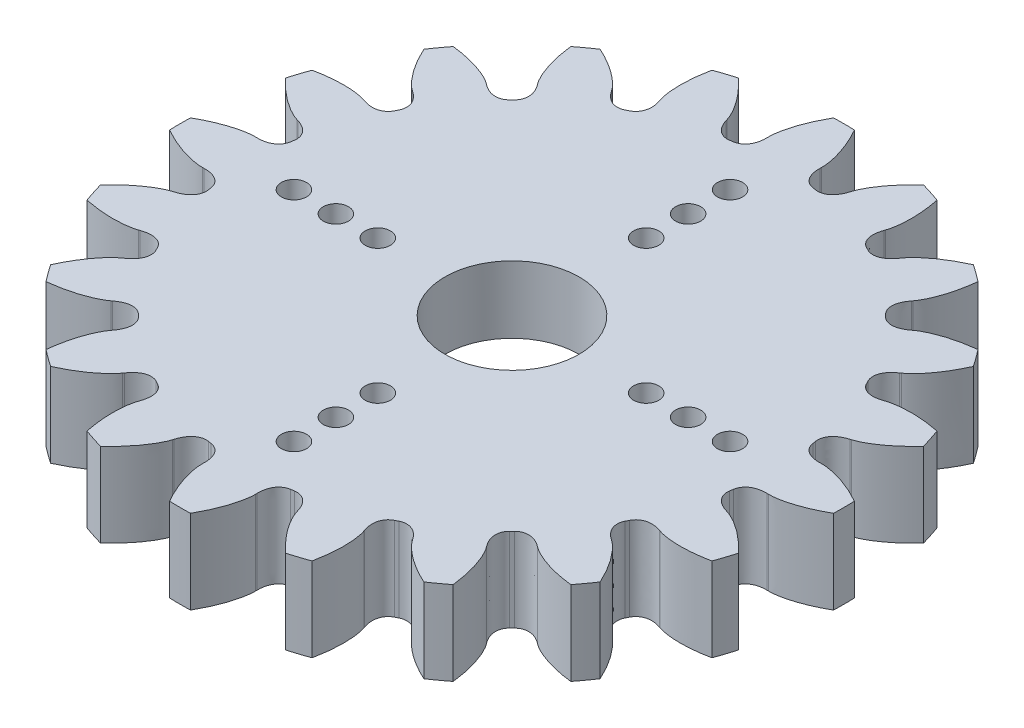
from build123d import *

# Parameters (mm, degrees)
BOSS_EXTRUDE1_DEPTH = 5
CUT_EXTRUDE2_DEPTH  = 1
FILLET1_R           = 2
SKETCH10_R          = 0.75
SKETCH10_R_2        = 4
CUT_EXTRUDE3_DEPTH  = 6.0000001


with BuildPart() as part:
    # Sketch7 → Boss-Extrude1 (new body)
    with BuildSketch(Plane(origin=(0, 0, 0), x_dir=(1, 0, 0), z_dir=(0, 1, 0))):
        with BuildLine():
            Line((-16.457739529, -3.687415298), (-16.52698002, -3.709016565))
            add(Edge.make_bspline(
                [(-16.52698002, -3.709016565), (-16.611903315, -3.73364132), (-16.770244428, -3.794438348), (-17.018736868, -3.912275662), (-17.295455662, -4.066469139), (-17.623414602, -4.278276885), (-17.995922824, -4.555042934), (-18.405597713, -4.903333775), (-18.747721316, -5.235290851), (-18.951522694, -5.45175861), (-19.014754844, -5.520787825)],
                knots=[0, 0, 0, 0, 0.062090842, 0.118994186, 0.193136179, 0.284516828, 0.393136137, 0.518994107, 0.662090741, 0.727860306, 0.727860306, 0.727860306, 0.727860306], degree=3))
            ThreePointArc((-19.014754844, -5.520787825), (-18.830919023, -6.118536489), (-18.628297477, -6.710181301))
            add(Edge.make_bspline(
                [(-18.628297477, -6.710181301), (-18.536567239, -6.728860183), (-18.244451904, -6.784194834), (-17.772548621, -6.851658542), (-17.236394454, -6.892630894), (-16.77234997, -6.897584492), (-16.382528145, -6.876171129), (-16.068025286, -6.838265047), (-15.797727644, -6.787537245), (-15.633891396, -6.743652502), (-15.550712939, -6.713657687)],
                knots=[0.272139694, 0.272139694, 0.272139694, 0.272139694, 0.337909259, 0.481005893, 0.606863863, 0.715483172, 0.806863821, 0.881005814, 0.937909158, 1, 1, 1, 1], degree=3))
            Line((-15.550712939, -6.713657687), (-15.4819993, -6.69043494))
            add(Edge.make_bspline(
                [(-15.4819993, -6.69043494), (-15.41523753, -6.666062876), (-15.302439181, -6.634063117), (-15.142393579, -6.602408879), (-15.003900862, -6.586966118), (-14.860356791, -6.585054534), (-14.708114194, -6.601356206), (-14.544296986, -6.644321677), (-14.299191223, -6.76133467), (-14.146581951, -6.923504613), (-14.079078982, -7.059889165)],
                knots=[0, 0, 0, 0, 0.134071962, 0.220864806, 0.307625499, 0.39666941, 0.491257897, 0.595715232, 0.714796253, 1, 1, 1, 1], degree=3))
            ThreePointArc((-14.079078982, -7.059889165), (-14.033352756, -7.150350371), (-13.987045304, -7.240515428))
            add(Edge.make_bspline(
                [(-13.987045304, -7.240515428), (-13.916385134, -7.375291306), (-13.874888373, -7.5940759), (-13.924292427, -7.86114914), (-13.985821969, -8.018934515), (-14.062119593, -8.151683246), (-14.148039184, -8.266689237), (-14.241936617, -8.369655172), (-14.361617878, -8.48052889), (-14.453807433, -8.552975685), (-14.51276643, -8.592661551)],
                knots=[0, 0, 0, 0, 0.285203747, 0.404284768, 0.508742103, 0.60333059, 0.692374501, 0.779135194, 0.865928038, 1, 1, 1, 1], degree=3))
            Line((-14.51276643, -8.592661551), (-14.571942892, -8.634602065))
            add(Edge.make_bspline(
                [(-14.571942892, -8.634602065), (-14.645100277, -8.68426434), (-14.77690431, -8.791015845), (-14.976820932, -8.979874177), (-15.192347738, -9.212031698), (-15.438803033, -9.51481772), (-15.707553992, -9.893149246), (-15.989550176, -10.350990023), (-16.212348679, -10.772421971), (-16.339283092, -11.041273133), (-16.37808924, -11.126463627)],
                knots=[0, 0, 0, 0, 0.062090842, 0.118994186, 0.193136179, 0.284516828, 0.393136137, 0.518994107, 0.662090741, 0.727860306, 0.727860306, 0.727860306, 0.727860306], degree=3))
            ThreePointArc((-16.37808924, -11.126463627), (-16.018536489, -11.638147995), (-15.643003646, -12.138222149))
            add(Edge.make_bspline(
                [(-15.643003646, -12.138222149), (-15.549990913, -12.127640619), (-15.255073373, -12.089998396), (-14.785419248, -12.008334062), (-14.262845181, -11.881620334), (-13.819981904, -11.742933854), (-13.45585641, -11.602106967), (-13.168460041, -11.468869412), (-12.92706746, -11.337097841), (-12.78481106, -11.244732785), (-12.714972554, -11.190502465)],
                knots=[0.272139694, 0.272139694, 0.272139694, 0.272139694, 0.337909259, 0.481005893, 0.606863863, 0.715483172, 0.806863821, 0.881005814, 0.937909158, 1, 1, 1, 1], degree=3))
            Line((-12.714972554, -11.190502465), (-12.656798223, -11.147182637))
            add(Edge.make_bspline(
                [(-12.656798223, -11.147182637), (-12.600835389, -11.103372905), (-12.503446253, -11.038082719), (-12.361015538, -10.958520939), (-12.234073213, -10.901037398), (-12.098145401, -10.854861816), (-11.948316593, -10.823320078), (-11.779240109, -10.813560368), (-11.509971672, -10.84910449), (-11.314718362, -10.956178413), (-11.208374079, -11.065028265)],
                knots=[0, 0, 0, 0, 0.134071962, 0.220864806, 0.307625499, 0.39666941, 0.491257897, 0.595715232, 0.714796253, 1, 1, 1, 1], degree=3))
            ThreePointArc((-11.208374079, -11.065028265), (-11.136931804, -11.136931804), (-11.065028265, -11.208374079))
            add(Edge.make_bspline(
                [(-11.065028265, -11.208374079), (-10.956178413, -11.314718362), (-10.84910449, -11.509971672), (-10.813560368, -11.779240109), (-10.823320078, -11.948316593), (-10.854861816, -12.098145401), (-10.901037398, -12.234073213), (-10.958520939, -12.361015538), (-11.038082719, -12.503446253), (-11.103372905, -12.600835389), (-11.147182637, -12.656798223)],
                knots=[0, 0, 0, 0, 0.285203747, 0.404284768, 0.508742103, 0.60333059, 0.692374501, 0.779135194, 0.865928038, 1, 1, 1, 1], degree=3))
            Line((-11.147182637, -12.656798223), (-11.190502465, -12.714972554))
            add(Edge.make_bspline(
                [(-11.190502465, -12.714972554), (-11.244732785, -12.78481106), (-11.337097841, -12.92706746), (-11.468869412, -13.168460041), (-11.602106967, -13.45585641), (-11.742933854, -13.819981904), (-11.881620334, -14.262845181), (-12.008334062, -14.785419248), (-12.089998396, -15.255073373), (-12.127640619, -15.549990913), (-12.138222149, -15.643003646)],
                knots=[0, 0, 0, 0, 0.062090842, 0.118994186, 0.193136179, 0.284516828, 0.393136137, 0.518994107, 0.662090741, 0.727860306, 0.727860306, 0.727860306, 0.727860306], degree=3))
            ThreePointArc((-12.138222149, -15.643003646), (-11.638147995, -16.018536489), (-11.126463627, -16.37808924))
            add(Edge.make_bspline(
                [(-11.126463627, -16.37808924), (-11.041273133, -16.339283092), (-10.772421971, -16.212348679), (-10.350990023, -15.989550176), (-9.893149246, -15.707553992), (-9.51481772, -15.438803033), (-9.212031698, -15.192347738), (-8.979874177, -14.976820932), (-8.791015845, -14.77690431), (-8.68426434, -14.645100277), (-8.634602065, -14.571942892)],
                knots=[0.272139694, 0.272139694, 0.272139694, 0.272139694, 0.337909259, 0.481005893, 0.606863863, 0.715483172, 0.806863821, 0.881005814, 0.937909158, 1, 1, 1, 1], degree=3))
            Line((-8.634602065, -14.571942892), (-8.592661551, -14.51276643))
            add(Edge.make_bspline(
                [(-8.592661551, -14.51276643), (-8.552975685, -14.453807433), (-8.48052889, -14.361617878), (-8.369655172, -14.241936617), (-8.266689237, -14.148039184), (-8.151683246, -14.062119593), (-8.018934515, -13.985821969), (-7.86114914, -13.924292427), (-7.5940759, -13.874888373), (-7.375291306, -13.916385134), (-7.240515428, -13.987045304)],
                knots=[0, 0, 0, 0, 0.134071962, 0.220864806, 0.307625499, 0.39666941, 0.491257897, 0.595715232, 0.714796253, 1, 1, 1, 1], degree=3))
            ThreePointArc((-7.240515428, -13.987045304), (-7.150350371, -14.033352756), (-7.059889165, -14.079078982))
            add(Edge.make_bspline(
                [(-7.059889165, -14.079078982), (-6.923504613, -14.146581951), (-6.76133467, -14.299191223), (-6.644321677, -14.544296986), (-6.601356206, -14.708114194), (-6.585054534, -14.860356791), (-6.586966118, -15.003900862), (-6.602408879, -15.142393579), (-6.634063117, -15.302439181), (-6.666062876, -15.41523753), (-6.69043494, -15.4819993)],
                knots=[0, 0, 0, 0, 0.285203747, 0.404284768, 0.508742103, 0.60333059, 0.692374501, 0.779135194, 0.865928038, 1, 1, 1, 1], degree=3))
            Line((-6.69043494, -15.4819993), (-6.713657687, -15.550712939))
            add(Edge.make_bspline(
                [(-6.713657687, -15.550712939), (-6.743652502, -15.633891396), (-6.787537245, -15.797727644), (-6.838265047, -16.068025286), (-6.876171129, -16.382528145), (-6.897584492, -16.77234997), (-6.892630894, -17.236394454), (-6.851658542, -17.772548621), (-6.784194834, -18.244451904), (-6.728860183, -18.536567239), (-6.710181301, -18.628297477)],
                knots=[0, 0, 0, 0, 0.062090842, 0.118994186, 0.193136179, 0.284516828, 0.393136137, 0.518994107, 0.662090741, 0.727860306, 0.727860306, 0.727860306, 0.727860306], degree=3))
            ThreePointArc((-6.710181301, -18.628297477), (-6.118536489, -18.830919023), (-5.520787825, -19.014754844))
            add(Edge.make_bspline(
                [(-5.520787825, -19.014754844), (-5.45175861, -18.951522694), (-5.235290851, -18.747721316), (-4.903333775, -18.405597713), (-4.555042934, -17.995922824), (-4.278276885, -17.623414602), (-4.066469139, -17.295455662), (-3.912275662, -17.018736868), (-3.794438348, -16.770244428), (-3.73364132, -16.611903315), (-3.709016565, -16.52698002)],
                knots=[0.272139694, 0.272139694, 0.272139694, 0.272139694, 0.337909259, 0.481005893, 0.606863863, 0.715483172, 0.806863821, 0.881005814, 0.937909158, 1, 1, 1, 1], degree=3))
            Line((-3.709016565, -16.52698002), (-3.687415298, -16.457739529))
            add(Edge.make_bspline(
                [(-3.687415298, -16.457739529), (-3.667891129, -16.389402584), (-3.627478271, -16.279337816), (-3.559014643, -16.131252309), (-3.490104122, -16.010132321), (-3.407277539, -15.892879127), (-3.304603255, -15.779294161), (-3.17355412, -15.672017727), (-2.934819068, -15.54250151), (-2.713919349, -15.514359117), (-2.563904679, -15.539912895)],
                knots=[0, 0, 0, 0, 0.134071962, 0.220864806, 0.307625499, 0.39666941, 0.491257897, 0.595715232, 0.714796253, 1, 1, 1, 1], degree=3))
            ThreePointArc((-2.563904679, -15.539912895), (-2.463842824, -15.556091364), (-2.363678924, -15.57162554))
            add(Edge.make_bspline(
                [(-2.363678924, -15.57162554), (-2.213109942, -15.593679534), (-2.011718303, -15.688706308), (-1.824690488, -15.885656738), (-1.733205595, -16.0281791), (-1.670656234, -16.167932921), (-1.628116701, -16.305042156), (-1.600007036, -16.441528633), (-1.580655195, -16.603522743), (-1.576232167, -16.720688818), (-1.578780856, -16.791714415)],
                knots=[0, 0, 0, 0, 0.285203747, 0.404284768, 0.508742103, 0.60333059, 0.692374501, 0.779135194, 0.865928038, 1, 1, 1, 1], degree=3))
            Line((-1.578780856, -16.791714415), (-1.579633319, -16.864241194))
            add(Edge.make_bspline(
                [(-1.579633319, -16.864241194), (-1.582456526, -16.952617514), (-1.573565212, -17.121996177), (-1.538283653, -17.394740264), (-1.477147752, -17.70556388), (-1.377051501, -18.08292356), (-1.228942718, -18.522725345), (-1.024294947, -19.019977107), (-0.814307014, -19.447936366), (-0.67141203, -19.708655212), (-0.625301155, -19.790123761)],
                knots=[0, 0, 0, 0, 0.062090842, 0.118994186, 0.193136179, 0.284516828, 0.393136137, 0.518994107, 0.662090741, 0.727860306, 0.727860306, 0.727860306, 0.727860306], degree=3))
            ThreePointArc((-0.625301155, -19.790123761), (0, -19.8), (0.625301155, -19.790123761))
            add(Edge.make_bspline(
                [(0.625301155, -19.790123761), (0.67141203, -19.708655212), (0.814307014, -19.447936366), (1.024294947, -19.019977107), (1.228942718, -18.522725345), (1.377051501, -18.08292356), (1.477147752, -17.70556388), (1.538283653, -17.394740264), (1.573565212, -17.121996177), (1.582456526, -16.952617514), (1.579633319, -16.864241194)],
                knots=[0.272139694, 0.272139694, 0.272139694, 0.272139694, 0.337909259, 0.481005893, 0.606863863, 0.715483172, 0.806863821, 0.881005814, 0.937909158, 1, 1, 1, 1], degree=3))
            Line((1.579633319, -16.864241194), (1.578780856, -16.791714415))
            add(Edge.make_bspline(
                [(1.578780856, -16.791714415), (1.576232167, -16.720688818), (1.580655195, -16.603522743), (1.600007036, -16.441528633), (1.628116701, -16.305042156), (1.670656234, -16.167932921), (1.733205595, -16.0281791), (1.824690488, -15.885656738), (2.011718303, -15.688706308), (2.213109942, -15.593679534), (2.363678924, -15.57162554)],
                knots=[0, 0, 0, 0, 0.134071962, 0.220864806, 0.307625499, 0.39666941, 0.491257897, 0.595715232, 0.714796253, 1, 1, 1, 1], degree=3))
            ThreePointArc((2.363678924, -15.57162554), (2.463842824, -15.556091364), (2.563904679, -15.539912895))
            add(Edge.make_bspline(
                [(2.563904679, -15.539912895), (2.713919349, -15.514359117), (2.934819068, -15.54250151), (3.17355412, -15.672017727), (3.304603255, -15.779294161), (3.407277539, -15.892879127), (3.490104122, -16.010132321), (3.559014643, -16.131252309), (3.627478271, -16.279337816), (3.667891129, -16.389402584), (3.687415298, -16.457739529)],
                knots=[0, 0, 0, 0, 0.285203747, 0.404284768, 0.508742103, 0.60333059, 0.692374501, 0.779135194, 0.865928038, 1, 1, 1, 1], degree=3))
            Line((3.687415298, -16.457739529), (3.709016565, -16.52698002))
            add(Edge.make_bspline(
                [(3.709016565, -16.52698002), (3.73364132, -16.611903315), (3.794438348, -16.770244428), (3.912275662, -17.018736868), (4.066469139, -17.295455662), (4.278276885, -17.623414602), (4.555042934, -17.995922824), (4.903333775, -18.405597713), (5.235290851, -18.747721316), (5.45175861, -18.951522694), (5.520787825, -19.014754844)],
                knots=[0, 0, 0, 0, 0.062090842, 0.118994186, 0.193136179, 0.284516828, 0.393136137, 0.518994107, 0.662090741, 0.727860306, 0.727860306, 0.727860306, 0.727860306], degree=3))
            ThreePointArc((5.520787825, -19.014754844), (6.118536489, -18.830919023), (6.710181301, -18.628297477))
            add(Edge.make_bspline(
                [(6.710181301, -18.628297477), (6.728860183, -18.536567239), (6.784194834, -18.244451904), (6.851658542, -17.772548621), (6.892630894, -17.236394454), (6.897584492, -16.77234997), (6.876171129, -16.382528145), (6.838265047, -16.068025286), (6.787537245, -15.797727644), (6.743652502, -15.633891396), (6.713657687, -15.550712939)],
                knots=[0.272139694, 0.272139694, 0.272139694, 0.272139694, 0.337909259, 0.481005893, 0.606863863, 0.715483172, 0.806863821, 0.881005814, 0.937909158, 1, 1, 1, 1], degree=3))
            Line((6.713657687, -15.550712939), (6.69043494, -15.4819993))
            add(Edge.make_bspline(
                [(6.69043494, -15.4819993), (6.666062876, -15.41523753), (6.634063117, -15.302439181), (6.602408879, -15.142393579), (6.586966118, -15.003900862), (6.585054534, -14.860356791), (6.601356206, -14.708114194), (6.644321677, -14.544296986), (6.76133467, -14.299191223), (6.923504613, -14.146581951), (7.059889165, -14.079078982)],
                knots=[0, 0, 0, 0, 0.134071962, 0.220864806, 0.307625499, 0.39666941, 0.491257897, 0.595715232, 0.714796253, 1, 1, 1, 1], degree=3))
            ThreePointArc((7.059889165, -14.079078982), (7.150350371, -14.033352756), (7.240515428, -13.987045304))
            add(Edge.make_bspline(
                [(7.240515428, -13.987045304), (7.375291306, -13.916385134), (7.5940759, -13.874888373), (7.86114914, -13.924292427), (8.018934515, -13.985821969), (8.151683246, -14.062119593), (8.266689237, -14.148039184), (8.369655172, -14.241936617), (8.48052889, -14.361617878), (8.552975685, -14.453807433), (8.592661551, -14.51276643)],
                knots=[0, 0, 0, 0, 0.285203747, 0.404284768, 0.508742103, 0.60333059, 0.692374501, 0.779135194, 0.865928038, 1, 1, 1, 1], degree=3))
            Line((8.592661551, -14.51276643), (8.634602065, -14.571942892))
            add(Edge.make_bspline(
                [(8.634602065, -14.571942892), (8.68426434, -14.645100277), (8.791015845, -14.77690431), (8.979874177, -14.976820932), (9.212031698, -15.192347738), (9.51481772, -15.438803033), (9.893149246, -15.707553992), (10.350990023, -15.989550176), (10.772421971, -16.212348679), (11.041273133, -16.339283092), (11.126463627, -16.37808924)],
                knots=[0, 0, 0, 0, 0.062090842, 0.118994186, 0.193136179, 0.284516828, 0.393136137, 0.518994107, 0.662090741, 0.727860306, 0.727860306, 0.727860306, 0.727860306], degree=3))
            ThreePointArc((11.126463627, -16.37808924), (11.638147995, -16.018536489), (12.138222149, -15.643003646))
            add(Edge.make_bspline(
                [(12.138222149, -15.643003646), (12.127640619, -15.549990913), (12.089998396, -15.255073373), (12.008334062, -14.785419248), (11.881620334, -14.262845181), (11.742933854, -13.819981904), (11.602106967, -13.45585641), (11.468869412, -13.168460041), (11.337097841, -12.92706746), (11.244732785, -12.78481106), (11.190502465, -12.714972554)],
                knots=[0.272139694, 0.272139694, 0.272139694, 0.272139694, 0.337909259, 0.481005893, 0.606863863, 0.715483172, 0.806863821, 0.881005814, 0.937909158, 1, 1, 1, 1], degree=3))
            Line((11.190502465, -12.714972554), (11.147182637, -12.656798223))
            add(Edge.make_bspline(
                [(11.147182637, -12.656798223), (11.103372905, -12.600835389), (11.038082719, -12.503446253), (10.958520939, -12.361015538), (10.901037398, -12.234073213), (10.854861816, -12.098145401), (10.823320078, -11.948316593), (10.813560368, -11.779240109), (10.84910449, -11.509971672), (10.956178413, -11.314718362), (11.065028265, -11.208374079)],
                knots=[0, 0, 0, 0, 0.134071962, 0.220864806, 0.307625499, 0.39666941, 0.491257897, 0.595715232, 0.714796253, 1, 1, 1, 1], degree=3))
            ThreePointArc((11.065028265, -11.208374079), (11.136931804, -11.136931804), (11.208374079, -11.065028265))
            add(Edge.make_bspline(
                [(11.208374079, -11.065028265), (11.314718362, -10.956178413), (11.509971672, -10.84910449), (11.779240109, -10.813560368), (11.948316593, -10.823320078), (12.098145401, -10.854861816), (12.234073213, -10.901037398), (12.361015538, -10.958520939), (12.503446253, -11.038082719), (12.600835389, -11.103372905), (12.656798223, -11.147182637)],
                knots=[0, 0, 0, 0, 0.285203747, 0.404284768, 0.508742103, 0.60333059, 0.692374501, 0.779135194, 0.865928038, 1, 1, 1, 1], degree=3))
            Line((12.656798223, -11.147182637), (12.714972554, -11.190502465))
            add(Edge.make_bspline(
                [(12.714972554, -11.190502465), (12.78481106, -11.244732785), (12.92706746, -11.337097841), (13.168460041, -11.468869412), (13.45585641, -11.602106967), (13.819981904, -11.742933854), (14.262845181, -11.881620334), (14.785419248, -12.008334062), (15.255073373, -12.089998396), (15.549990913, -12.127640619), (15.643003646, -12.138222149)],
                knots=[0, 0, 0, 0, 0.062090842, 0.118994186, 0.193136179, 0.284516828, 0.393136137, 0.518994107, 0.662090741, 0.727860306, 0.727860306, 0.727860306, 0.727860306], degree=3))
            ThreePointArc((15.643003646, -12.138222149), (16.018536489, -11.638147995), (16.37808924, -11.126463627))
            add(Edge.make_bspline(
                [(16.37808924, -11.126463627), (16.339283092, -11.041273133), (16.212348679, -10.772421971), (15.989550176, -10.350990023), (15.707553992, -9.893149246), (15.438803033, -9.51481772), (15.192347738, -9.212031698), (14.976820932, -8.979874177), (14.77690431, -8.791015845), (14.645100277, -8.68426434), (14.571942892, -8.634602065)],
                knots=[0.272139694, 0.272139694, 0.272139694, 0.272139694, 0.337909259, 0.481005893, 0.606863863, 0.715483172, 0.806863821, 0.881005814, 0.937909158, 1, 1, 1, 1], degree=3))
            Line((14.571942892, -8.634602065), (14.51276643, -8.592661551))
            add(Edge.make_bspline(
                [(14.51276643, -8.592661551), (14.453807433, -8.552975685), (14.361617878, -8.48052889), (14.241936617, -8.369655172), (14.148039184, -8.266689237), (14.062119593, -8.151683246), (13.985821969, -8.018934515), (13.924292427, -7.86114914), (13.874888373, -7.5940759), (13.916385134, -7.375291306), (13.987045304, -7.240515428)],
                knots=[0, 0, 0, 0, 0.134071962, 0.220864806, 0.307625499, 0.39666941, 0.491257897, 0.595715232, 0.714796253, 1, 1, 1, 1], degree=3))
            ThreePointArc((13.987045304, -7.240515428), (14.033352756, -7.150350371), (14.079078982, -7.059889165))
            add(Edge.make_bspline(
                [(14.079078982, -7.059889165), (14.146581951, -6.923504613), (14.299191223, -6.76133467), (14.544296986, -6.644321677), (14.708114194, -6.601356206), (14.860356791, -6.585054534), (15.003900862, -6.586966118), (15.142393579, -6.602408879), (15.302439181, -6.634063117), (15.41523753, -6.666062876), (15.4819993, -6.69043494)],
                knots=[0, 0, 0, 0, 0.285203747, 0.404284768, 0.508742103, 0.60333059, 0.692374501, 0.779135194, 0.865928038, 1, 1, 1, 1], degree=3))
            Line((15.4819993, -6.69043494), (15.550712939, -6.713657687))
            add(Edge.make_bspline(
                [(15.550712939, -6.713657687), (15.633891396, -6.743652502), (15.797727644, -6.787537245), (16.068025286, -6.838265047), (16.382528145, -6.876171129), (16.77234997, -6.897584492), (17.236394454, -6.892630894), (17.772548621, -6.851658542), (18.244451904, -6.784194834), (18.536567239, -6.728860183), (18.628297477, -6.710181301)],
                knots=[0, 0, 0, 0, 0.062090842, 0.118994186, 0.193136179, 0.284516828, 0.393136137, 0.518994107, 0.662090741, 0.727860306, 0.727860306, 0.727860306, 0.727860306], degree=3))
            ThreePointArc((18.628297477, -6.710181301), (18.830919023, -6.118536489), (19.014754844, -5.520787825))
            add(Edge.make_bspline(
                [(19.014754844, -5.520787825), (18.951522694, -5.45175861), (18.747721316, -5.235290851), (18.405597713, -4.903333775), (17.995922824, -4.555042934), (17.623414602, -4.278276885), (17.295455662, -4.066469139), (17.018736868, -3.912275662), (16.770244428, -3.794438348), (16.611903315, -3.73364132), (16.52698002, -3.709016565)],
                knots=[0.272139694, 0.272139694, 0.272139694, 0.272139694, 0.337909259, 0.481005893, 0.606863863, 0.715483172, 0.806863821, 0.881005814, 0.937909158, 1, 1, 1, 1], degree=3))
            Line((16.52698002, -3.709016565), (16.457739529, -3.687415298))
            add(Edge.make_bspline(
                [(16.457739529, -3.687415298), (16.389402584, -3.667891129), (16.279337816, -3.627478271), (16.131252309, -3.559014643), (16.010132321, -3.490104122), (15.892879127, -3.407277539), (15.779294161, -3.304603255), (15.672017727, -3.17355412), (15.54250151, -2.934819068), (15.514359117, -2.713919349), (15.539912895, -2.563904679)],
                knots=[0, 0, 0, 0, 0.134071962, 0.220864806, 0.307625499, 0.39666941, 0.491257897, 0.595715232, 0.714796253, 1, 1, 1, 1], degree=3))
            ThreePointArc((15.539912895, -2.563904679), (15.556091364, -2.463842824), (15.57162554, -2.363678924))
            add(Edge.make_bspline(
                [(15.57162554, -2.363678924), (15.593679534, -2.213109942), (15.688706308, -2.011718303), (15.885656738, -1.824690488), (16.0281791, -1.733205595), (16.167932921, -1.670656234), (16.305042156, -1.628116701), (16.441528633, -1.600007036), (16.603522743, -1.580655195), (16.720688818, -1.576232167), (16.791714415, -1.578780856)],
                knots=[0, 0, 0, 0, 0.285203747, 0.404284768, 0.508742103, 0.60333059, 0.692374501, 0.779135194, 0.865928038, 1, 1, 1, 1], degree=3))
            Line((16.791714415, -1.578780856), (16.864241194, -1.579633319))
            add(Edge.make_bspline(
                [(16.864241194, -1.579633319), (16.952617514, -1.582456526), (17.121996177, -1.573565212), (17.394740264, -1.538283653), (17.70556388, -1.477147752), (18.08292356, -1.377051501), (18.522725345, -1.228942718), (19.019977107, -1.024294947), (19.447936366, -0.814307014), (19.708655212, -0.67141203), (19.790123761, -0.625301155)],
                knots=[0, 0, 0, 0, 0.062090842, 0.118994186, 0.193136179, 0.284516828, 0.393136137, 0.518994107, 0.662090741, 0.727860306, 0.727860306, 0.727860306, 0.727860306], degree=3))
            ThreePointArc((19.790123761, -0.625301155), (19.8, 0), (19.790123761, 0.625301155))
            add(Edge.make_bspline(
                [(19.790123761, 0.625301155), (19.708655212, 0.67141203), (19.447936366, 0.814307014), (19.019977107, 1.024294947), (18.522725345, 1.228942718), (18.08292356, 1.377051501), (17.70556388, 1.477147752), (17.394740264, 1.538283653), (17.121996177, 1.573565212), (16.952617514, 1.582456526), (16.864241194, 1.579633319)],
                knots=[0.272139694, 0.272139694, 0.272139694, 0.272139694, 0.337909259, 0.481005893, 0.606863863, 0.715483172, 0.806863821, 0.881005814, 0.937909158, 1, 1, 1, 1], degree=3))
            Line((16.864241194, 1.579633319), (16.791714415, 1.578780856))
            add(Edge.make_bspline(
                [(16.791714415, 1.578780856), (16.720688818, 1.576232167), (16.603522743, 1.580655195), (16.441528633, 1.600007036), (16.305042156, 1.628116701), (16.167932921, 1.670656234), (16.0281791, 1.733205595), (15.885656738, 1.824690488), (15.688706308, 2.011718303), (15.593679534, 2.213109942), (15.57162554, 2.363678924)],
                knots=[0, 0, 0, 0, 0.134071962, 0.220864806, 0.307625499, 0.39666941, 0.491257897, 0.595715232, 0.714796253, 1, 1, 1, 1], degree=3))
            ThreePointArc((15.57162554, 2.363678924), (15.556091364, 2.463842824), (15.539912895, 2.563904679))
            add(Edge.make_bspline(
                [(15.539912895, 2.563904679), (15.514359117, 2.713919349), (15.54250151, 2.934819068), (15.672017727, 3.17355412), (15.779294161, 3.304603255), (15.892879127, 3.407277539), (16.010132321, 3.490104122), (16.131252309, 3.559014643), (16.279337816, 3.627478271), (16.389402584, 3.667891129), (16.457739529, 3.687415298)],
                knots=[0, 0, 0, 0, 0.285203747, 0.404284768, 0.508742103, 0.60333059, 0.692374501, 0.779135194, 0.865928038, 1, 1, 1, 1], degree=3))
            Line((16.457739529, 3.687415298), (16.52698002, 3.709016565))
            add(Edge.make_bspline(
                [(16.52698002, 3.709016565), (16.611903315, 3.73364132), (16.770244428, 3.794438348), (17.018736868, 3.912275662), (17.295455662, 4.066469139), (17.623414602, 4.278276885), (17.995922824, 4.555042934), (18.405597713, 4.903333775), (18.747721316, 5.235290851), (18.951522694, 5.45175861), (19.014754844, 5.520787825)],
                knots=[0, 0, 0, 0, 0.062090842, 0.118994186, 0.193136179, 0.284516828, 0.393136137, 0.518994107, 0.662090741, 0.727860306, 0.727860306, 0.727860306, 0.727860306], degree=3))
            ThreePointArc((19.014754844, 5.520787825), (18.830919023, 6.118536489), (18.628297477, 6.710181301))
            add(Edge.make_bspline(
                [(18.628297477, 6.710181301), (18.536567239, 6.728860183), (18.244451904, 6.784194834), (17.772548621, 6.851658542), (17.236394454, 6.892630894), (16.77234997, 6.897584492), (16.382528145, 6.876171129), (16.068025286, 6.838265047), (15.797727644, 6.787537245), (15.633891396, 6.743652502), (15.550712939, 6.713657687)],
                knots=[0.272139694, 0.272139694, 0.272139694, 0.272139694, 0.337909259, 0.481005893, 0.606863863, 0.715483172, 0.806863821, 0.881005814, 0.937909158, 1, 1, 1, 1], degree=3))
            Line((15.550712939, 6.713657687), (15.4819993, 6.69043494))
            add(Edge.make_bspline(
                [(15.4819993, 6.69043494), (15.41523753, 6.666062876), (15.302439181, 6.634063117), (15.142393579, 6.602408879), (15.003900862, 6.586966118), (14.860356791, 6.585054534), (14.708114194, 6.601356206), (14.544296986, 6.644321677), (14.299191223, 6.76133467), (14.146581951, 6.923504613), (14.079078982, 7.059889165)],
                knots=[0, 0, 0, 0, 0.134071962, 0.220864806, 0.307625499, 0.39666941, 0.491257897, 0.595715232, 0.714796253, 1, 1, 1, 1], degree=3))
            ThreePointArc((14.079078982, 7.059889165), (14.033352756, 7.150350371), (13.987045304, 7.240515428))
            add(Edge.make_bspline(
                [(13.987045304, 7.240515428), (13.916385134, 7.375291306), (13.874888373, 7.5940759), (13.924292427, 7.86114914), (13.985821969, 8.018934515), (14.062119593, 8.151683246), (14.148039184, 8.266689237), (14.241936617, 8.369655172), (14.361617878, 8.48052889), (14.453807433, 8.552975685), (14.51276643, 8.592661551)],
                knots=[0, 0, 0, 0, 0.285203747, 0.404284768, 0.508742103, 0.60333059, 0.692374501, 0.779135194, 0.865928038, 1, 1, 1, 1], degree=3))
            Line((14.51276643, 8.592661551), (14.571942892, 8.634602065))
            add(Edge.make_bspline(
                [(14.571942892, 8.634602065), (14.645100277, 8.68426434), (14.77690431, 8.791015845), (14.976820932, 8.979874177), (15.192347738, 9.212031698), (15.438803033, 9.51481772), (15.707553992, 9.893149246), (15.989550176, 10.350990023), (16.212348679, 10.772421971), (16.339283092, 11.041273133), (16.37808924, 11.126463627)],
                knots=[0, 0, 0, 0, 0.062090842, 0.118994186, 0.193136179, 0.284516828, 0.393136137, 0.518994107, 0.662090741, 0.727860306, 0.727860306, 0.727860306, 0.727860306], degree=3))
            ThreePointArc((16.37808924, 11.126463627), (16.018536489, 11.638147995), (15.643003646, 12.138222149))
            add(Edge.make_bspline(
                [(15.643003646, 12.138222149), (15.549990913, 12.127640619), (15.255073373, 12.089998396), (14.785419248, 12.008334062), (14.262845181, 11.881620334), (13.819981904, 11.742933854), (13.45585641, 11.602106967), (13.168460041, 11.468869412), (12.92706746, 11.337097841), (12.78481106, 11.244732785), (12.714972554, 11.190502465)],
                knots=[0.272139694, 0.272139694, 0.272139694, 0.272139694, 0.337909259, 0.481005893, 0.606863863, 0.715483172, 0.806863821, 0.881005814, 0.937909158, 1, 1, 1, 1], degree=3))
            Line((12.714972554, 11.190502465), (12.656798223, 11.147182637))
            add(Edge.make_bspline(
                [(12.656798223, 11.147182637), (12.600835389, 11.103372905), (12.503446253, 11.038082719), (12.361015538, 10.958520939), (12.234073213, 10.901037398), (12.098145401, 10.854861816), (11.948316593, 10.823320078), (11.779240109, 10.813560368), (11.509971672, 10.84910449), (11.314718362, 10.956178413), (11.208374079, 11.065028265)],
                knots=[0, 0, 0, 0, 0.134071962, 0.220864806, 0.307625499, 0.39666941, 0.491257897, 0.595715232, 0.714796253, 1, 1, 1, 1], degree=3))
            ThreePointArc((11.208374079, 11.065028265), (11.136931804, 11.136931804), (11.065028265, 11.208374079))
            add(Edge.make_bspline(
                [(11.065028265, 11.208374079), (10.956178413, 11.314718362), (10.84910449, 11.509971672), (10.813560368, 11.779240109), (10.823320078, 11.948316593), (10.854861816, 12.098145401), (10.901037398, 12.234073213), (10.958520939, 12.361015538), (11.038082719, 12.503446253), (11.103372905, 12.600835389), (11.147182637, 12.656798223)],
                knots=[0, 0, 0, 0, 0.285203747, 0.404284768, 0.508742103, 0.60333059, 0.692374501, 0.779135194, 0.865928038, 1, 1, 1, 1], degree=3))
            Line((11.147182637, 12.656798223), (11.190502465, 12.714972554))
            add(Edge.make_bspline(
                [(11.190502465, 12.714972554), (11.244732785, 12.78481106), (11.337097841, 12.92706746), (11.468869412, 13.168460041), (11.602106967, 13.45585641), (11.742933854, 13.819981904), (11.881620334, 14.262845181), (12.008334062, 14.785419248), (12.089998396, 15.255073373), (12.127640619, 15.549990913), (12.138222149, 15.643003646)],
                knots=[0, 0, 0, 0, 0.062090842, 0.118994186, 0.193136179, 0.284516828, 0.393136137, 0.518994107, 0.662090741, 0.727860306, 0.727860306, 0.727860306, 0.727860306], degree=3))
            ThreePointArc((12.138222149, 15.643003646), (11.638147995, 16.018536489), (11.126463627, 16.37808924))
            add(Edge.make_bspline(
                [(11.126463627, 16.37808924), (11.041273133, 16.339283092), (10.772421971, 16.212348679), (10.350990023, 15.989550176), (9.893149246, 15.707553992), (9.51481772, 15.438803033), (9.212031698, 15.192347738), (8.979874177, 14.976820932), (8.791015845, 14.77690431), (8.68426434, 14.645100277), (8.634602065, 14.571942892)],
                knots=[0.272139694, 0.272139694, 0.272139694, 0.272139694, 0.337909259, 0.481005893, 0.606863863, 0.715483172, 0.806863821, 0.881005814, 0.937909158, 1, 1, 1, 1], degree=3))
            Line((8.634602065, 14.571942892), (8.592661551, 14.51276643))
            add(Edge.make_bspline(
                [(8.592661551, 14.51276643), (8.552975685, 14.453807433), (8.48052889, 14.361617878), (8.369655172, 14.241936617), (8.266689237, 14.148039184), (8.151683246, 14.062119593), (8.018934515, 13.985821969), (7.86114914, 13.924292427), (7.5940759, 13.874888373), (7.375291306, 13.916385134), (7.240515428, 13.987045304)],
                knots=[0, 0, 0, 0, 0.134071962, 0.220864806, 0.307625499, 0.39666941, 0.491257897, 0.595715232, 0.714796253, 1, 1, 1, 1], degree=3))
            ThreePointArc((7.240515428, 13.987045304), (7.150350371, 14.033352756), (7.059889165, 14.079078982))
            add(Edge.make_bspline(
                [(7.059889165, 14.079078982), (6.923504613, 14.146581951), (6.76133467, 14.299191223), (6.644321677, 14.544296986), (6.601356206, 14.708114194), (6.585054534, 14.860356791), (6.586966118, 15.003900862), (6.602408879, 15.142393579), (6.634063117, 15.302439181), (6.666062876, 15.41523753), (6.69043494, 15.4819993)],
                knots=[0, 0, 0, 0, 0.285203747, 0.404284768, 0.508742103, 0.60333059, 0.692374501, 0.779135194, 0.865928038, 1, 1, 1, 1], degree=3))
            Line((6.69043494, 15.4819993), (6.713657687, 15.550712939))
            add(Edge.make_bspline(
                [(6.713657687, 15.550712939), (6.743652502, 15.633891396), (6.787537245, 15.797727644), (6.838265047, 16.068025286), (6.876171129, 16.382528145), (6.897584492, 16.77234997), (6.892630894, 17.236394454), (6.851658542, 17.772548621), (6.784194834, 18.244451904), (6.728860183, 18.536567239), (6.710181301, 18.628297477)],
                knots=[0, 0, 0, 0, 0.062090842, 0.118994186, 0.193136179, 0.284516828, 0.393136137, 0.518994107, 0.662090741, 0.727860306, 0.727860306, 0.727860306, 0.727860306], degree=3))
            ThreePointArc((6.710181301, 18.628297477), (6.118536489, 18.830919023), (5.520787825, 19.014754844))
            add(Edge.make_bspline(
                [(5.520787825, 19.014754844), (5.45175861, 18.951522694), (5.235290851, 18.747721316), (4.903333775, 18.405597713), (4.555042934, 17.995922824), (4.278276885, 17.623414602), (4.066469139, 17.295455662), (3.912275662, 17.018736868), (3.794438348, 16.770244428), (3.73364132, 16.611903315), (3.709016565, 16.52698002)],
                knots=[0.272139694, 0.272139694, 0.272139694, 0.272139694, 0.337909259, 0.481005893, 0.606863863, 0.715483172, 0.806863821, 0.881005814, 0.937909158, 1, 1, 1, 1], degree=3))
            Line((3.709016565, 16.52698002), (3.687415298, 16.457739529))
            add(Edge.make_bspline(
                [(3.687415298, 16.457739529), (3.667891129, 16.389402584), (3.627478271, 16.279337816), (3.559014643, 16.131252309), (3.490104122, 16.010132321), (3.407277539, 15.892879127), (3.304603255, 15.779294161), (3.17355412, 15.672017727), (2.934819068, 15.54250151), (2.713919349, 15.514359117), (2.563904679, 15.539912895)],
                knots=[0, 0, 0, 0, 0.134071962, 0.220864806, 0.307625499, 0.39666941, 0.491257897, 0.595715232, 0.714796253, 1, 1, 1, 1], degree=3))
            ThreePointArc((2.563904679, 15.539912895), (2.463842824, 15.556091364), (2.363678924, 15.57162554))
            add(Edge.make_bspline(
                [(2.363678924, 15.57162554), (2.213109942, 15.593679534), (2.011718303, 15.688706308), (1.824690488, 15.885656738), (1.733205595, 16.0281791), (1.670656234, 16.167932921), (1.628116701, 16.305042156), (1.600007036, 16.441528633), (1.580655195, 16.603522743), (1.576232167, 16.720688818), (1.578780856, 16.791714415)],
                knots=[0, 0, 0, 0, 0.285203747, 0.404284768, 0.508742103, 0.60333059, 0.692374501, 0.779135194, 0.865928038, 1, 1, 1, 1], degree=3))
            Line((1.578780856, 16.791714415), (1.579633319, 16.864241194))
            add(Edge.make_bspline(
                [(1.579633319, 16.864241194), (1.582456526, 16.952617514), (1.573565212, 17.121996177), (1.538283653, 17.394740264), (1.477147752, 17.70556388), (1.377051501, 18.08292356), (1.228942718, 18.522725345), (1.024294947, 19.019977107), (0.814307014, 19.447936366), (0.67141203, 19.708655212), (0.625301155, 19.790123761)],
                knots=[0, 0, 0, 0, 0.062090842, 0.118994186, 0.193136179, 0.284516828, 0.393136137, 0.518994107, 0.662090741, 0.727860306, 0.727860306, 0.727860306, 0.727860306], degree=3))
            ThreePointArc((0.625301155, 19.790123761), (0, 19.8), (-0.625301155, 19.790123761))
            add(Edge.make_bspline(
                [(-0.625301155, 19.790123761), (-0.67141203, 19.708655212), (-0.814307014, 19.447936366), (-1.024294947, 19.019977107), (-1.228942718, 18.522725345), (-1.377051501, 18.08292356), (-1.477147752, 17.70556388), (-1.538283653, 17.394740264), (-1.573565212, 17.121996177), (-1.582456526, 16.952617514), (-1.579633319, 16.864241194)],
                knots=[0.272139694, 0.272139694, 0.272139694, 0.272139694, 0.337909259, 0.481005893, 0.606863863, 0.715483172, 0.806863821, 0.881005814, 0.937909158, 1, 1, 1, 1], degree=3))
            Line((-1.579633319, 16.864241194), (-1.578780856, 16.791714415))
            add(Edge.make_bspline(
                [(-1.578780856, 16.791714415), (-1.576232167, 16.720688818), (-1.580655195, 16.603522743), (-1.600007036, 16.441528633), (-1.628116701, 16.305042156), (-1.670656234, 16.167932921), (-1.733205595, 16.0281791), (-1.824690488, 15.885656738), (-2.011718303, 15.688706308), (-2.213109942, 15.593679534), (-2.363678924, 15.57162554)],
                knots=[0, 0, 0, 0, 0.134071962, 0.220864806, 0.307625499, 0.39666941, 0.491257897, 0.595715232, 0.714796253, 1, 1, 1, 1], degree=3))
            ThreePointArc((-2.363678924, 15.57162554), (-2.463842824, 15.556091364), (-2.563904679, 15.539912895))
            add(Edge.make_bspline(
                [(-2.563904679, 15.539912895), (-2.713919349, 15.514359117), (-2.934819068, 15.54250151), (-3.17355412, 15.672017727), (-3.304603255, 15.779294161), (-3.407277539, 15.892879127), (-3.490104122, 16.010132321), (-3.559014643, 16.131252309), (-3.627478271, 16.279337816), (-3.667891129, 16.389402584), (-3.687415298, 16.457739529)],
                knots=[0, 0, 0, 0, 0.285203747, 0.404284768, 0.508742103, 0.60333059, 0.692374501, 0.779135194, 0.865928038, 1, 1, 1, 1], degree=3))
            Line((-3.687415298, 16.457739529), (-3.709016565, 16.52698002))
            add(Edge.make_bspline(
                [(-3.709016565, 16.52698002), (-3.73364132, 16.611903315), (-3.794438348, 16.770244428), (-3.912275662, 17.018736868), (-4.066469139, 17.295455662), (-4.278276885, 17.623414602), (-4.555042934, 17.995922824), (-4.903333775, 18.405597713), (-5.235290851, 18.747721316), (-5.45175861, 18.951522694), (-5.520787825, 19.014754844)],
                knots=[0, 0, 0, 0, 0.062090842, 0.118994186, 0.193136179, 0.284516828, 0.393136137, 0.518994107, 0.662090741, 0.727860306, 0.727860306, 0.727860306, 0.727860306], degree=3))
            ThreePointArc((-5.520787825, 19.014754844), (-6.118536489, 18.830919023), (-6.710181301, 18.628297477))
            add(Edge.make_bspline(
                [(-6.710181301, 18.628297477), (-6.728860183, 18.536567239), (-6.784194834, 18.244451904), (-6.851658542, 17.772548621), (-6.892630894, 17.236394454), (-6.897584492, 16.77234997), (-6.876171129, 16.382528145), (-6.838265047, 16.068025286), (-6.787537245, 15.797727644), (-6.743652502, 15.633891396), (-6.713657687, 15.550712939)],
                knots=[0.272139694, 0.272139694, 0.272139694, 0.272139694, 0.337909259, 0.481005893, 0.606863863, 0.715483172, 0.806863821, 0.881005814, 0.937909158, 1, 1, 1, 1], degree=3))
            Line((-6.713657687, 15.550712939), (-6.69043494, 15.4819993))
            add(Edge.make_bspline(
                [(-6.69043494, 15.4819993), (-6.666062876, 15.41523753), (-6.634063117, 15.302439181), (-6.602408879, 15.142393579), (-6.586966118, 15.003900862), (-6.585054534, 14.860356791), (-6.601356206, 14.708114194), (-6.644321677, 14.544296986), (-6.76133467, 14.299191223), (-6.923504613, 14.146581951), (-7.059889165, 14.079078982)],
                knots=[0, 0, 0, 0, 0.134071962, 0.220864806, 0.307625499, 0.39666941, 0.491257897, 0.595715232, 0.714796253, 1, 1, 1, 1], degree=3))
            ThreePointArc((-7.059889165, 14.079078982), (-7.150350371, 14.033352756), (-7.240515428, 13.987045304))
            add(Edge.make_bspline(
                [(-7.240515428, 13.987045304), (-7.375291306, 13.916385134), (-7.5940759, 13.874888373), (-7.86114914, 13.924292427), (-8.018934515, 13.985821969), (-8.151683246, 14.062119593), (-8.266689237, 14.148039184), (-8.369655172, 14.241936617), (-8.48052889, 14.361617878), (-8.552975685, 14.453807433), (-8.592661551, 14.51276643)],
                knots=[0, 0, 0, 0, 0.285203747, 0.404284768, 0.508742103, 0.60333059, 0.692374501, 0.779135194, 0.865928038, 1, 1, 1, 1], degree=3))
            Line((-8.592661551, 14.51276643), (-8.634602065, 14.571942892))
            add(Edge.make_bspline(
                [(-8.634602065, 14.571942892), (-8.68426434, 14.645100277), (-8.791015845, 14.77690431), (-8.979874177, 14.976820932), (-9.212031698, 15.192347738), (-9.51481772, 15.438803033), (-9.893149246, 15.707553992), (-10.350990023, 15.989550176), (-10.772421971, 16.212348679), (-11.041273133, 16.339283092), (-11.126463627, 16.37808924)],
                knots=[0, 0, 0, 0, 0.062090842, 0.118994186, 0.193136179, 0.284516828, 0.393136137, 0.518994107, 0.662090741, 0.727860306, 0.727860306, 0.727860306, 0.727860306], degree=3))
            ThreePointArc((-11.126463627, 16.37808924), (-11.638147995, 16.018536489), (-12.138222149, 15.643003646))
            add(Edge.make_bspline(
                [(-12.138222149, 15.643003646), (-12.127640619, 15.549990913), (-12.089998396, 15.255073373), (-12.008334062, 14.785419248), (-11.881620334, 14.262845181), (-11.742933854, 13.819981904), (-11.602106967, 13.45585641), (-11.468869412, 13.168460041), (-11.337097841, 12.92706746), (-11.244732785, 12.78481106), (-11.190502465, 12.714972554)],
                knots=[0.272139694, 0.272139694, 0.272139694, 0.272139694, 0.337909259, 0.481005893, 0.606863863, 0.715483172, 0.806863821, 0.881005814, 0.937909158, 1, 1, 1, 1], degree=3))
            Line((-11.190502465, 12.714972554), (-11.147182637, 12.656798223))
            add(Edge.make_bspline(
                [(-11.147182637, 12.656798223), (-11.103372905, 12.600835389), (-11.038082719, 12.503446253), (-10.958520939, 12.361015538), (-10.901037398, 12.234073213), (-10.854861816, 12.098145401), (-10.823320078, 11.948316593), (-10.813560368, 11.779240109), (-10.84910449, 11.509971672), (-10.956178413, 11.314718362), (-11.065028265, 11.208374079)],
                knots=[0, 0, 0, 0, 0.134071962, 0.220864806, 0.307625499, 0.39666941, 0.491257897, 0.595715232, 0.714796253, 1, 1, 1, 1], degree=3))
            ThreePointArc((-11.065028265, 11.208374079), (-11.136931804, 11.136931804), (-11.208374079, 11.065028265))
            add(Edge.make_bspline(
                [(-11.208374079, 11.065028265), (-11.314718362, 10.956178413), (-11.509971672, 10.84910449), (-11.779240109, 10.813560368), (-11.948316593, 10.823320078), (-12.098145401, 10.854861816), (-12.234073213, 10.901037398), (-12.361015538, 10.958520939), (-12.503446253, 11.038082719), (-12.600835389, 11.103372905), (-12.656798223, 11.147182637)],
                knots=[0, 0, 0, 0, 0.285203747, 0.404284768, 0.508742103, 0.60333059, 0.692374501, 0.779135194, 0.865928038, 1, 1, 1, 1], degree=3))
            Line((-12.656798223, 11.147182637), (-12.714972554, 11.190502465))
            add(Edge.make_bspline(
                [(-12.714972554, 11.190502465), (-12.78481106, 11.244732785), (-12.92706746, 11.337097841), (-13.168460041, 11.468869412), (-13.45585641, 11.602106967), (-13.819981904, 11.742933854), (-14.262845181, 11.881620334), (-14.785419248, 12.008334062), (-15.255073373, 12.089998396), (-15.549990913, 12.127640619), (-15.643003646, 12.138222149)],
                knots=[0, 0, 0, 0, 0.062090842, 0.118994186, 0.193136179, 0.284516828, 0.393136137, 0.518994107, 0.662090741, 0.727860306, 0.727860306, 0.727860306, 0.727860306], degree=3))
            ThreePointArc((-15.643003646, 12.138222149), (-16.018536489, 11.638147995), (-16.37808924, 11.126463627))
            add(Edge.make_bspline(
                [(-16.37808924, 11.126463627), (-16.339283092, 11.041273133), (-16.212348679, 10.772421971), (-15.989550176, 10.350990023), (-15.707553992, 9.893149246), (-15.438803033, 9.51481772), (-15.192347738, 9.212031698), (-14.976820932, 8.979874177), (-14.77690431, 8.791015845), (-14.645100277, 8.68426434), (-14.571942892, 8.634602065)],
                knots=[0.272139694, 0.272139694, 0.272139694, 0.272139694, 0.337909259, 0.481005893, 0.606863863, 0.715483172, 0.806863821, 0.881005814, 0.937909158, 1, 1, 1, 1], degree=3))
            Line((-14.571942892, 8.634602065), (-14.51276643, 8.592661551))
            add(Edge.make_bspline(
                [(-14.51276643, 8.592661551), (-14.453807433, 8.552975685), (-14.361617878, 8.48052889), (-14.241936617, 8.369655172), (-14.148039184, 8.266689237), (-14.062119593, 8.151683246), (-13.985821969, 8.018934515), (-13.924292427, 7.86114914), (-13.874888373, 7.5940759), (-13.916385134, 7.375291306), (-13.987045304, 7.240515428)],
                knots=[0, 0, 0, 0, 0.134071962, 0.220864806, 0.307625499, 0.39666941, 0.491257897, 0.595715232, 0.714796253, 1, 1, 1, 1], degree=3))
            ThreePointArc((-13.987045304, 7.240515428), (-14.033352756, 7.150350371), (-14.079078982, 7.059889165))
            add(Edge.make_bspline(
                [(-14.079078982, 7.059889165), (-14.146581951, 6.923504613), (-14.299191223, 6.76133467), (-14.544296986, 6.644321677), (-14.708114194, 6.601356206), (-14.860356791, 6.585054534), (-15.003900862, 6.586966118), (-15.142393579, 6.602408879), (-15.302439181, 6.634063117), (-15.41523753, 6.666062876), (-15.4819993, 6.69043494)],
                knots=[0, 0, 0, 0, 0.285203747, 0.404284768, 0.508742103, 0.60333059, 0.692374501, 0.779135194, 0.865928038, 1, 1, 1, 1], degree=3))
            Line((-15.4819993, 6.69043494), (-15.550712939, 6.713657687))
            add(Edge.make_bspline(
                [(-15.550712939, 6.713657687), (-15.633891396, 6.743652502), (-15.797727644, 6.787537245), (-16.068025286, 6.838265047), (-16.382528145, 6.876171129), (-16.77234997, 6.897584492), (-17.236394454, 6.892630894), (-17.772548621, 6.851658542), (-18.244451904, 6.784194834), (-18.536567239, 6.728860183), (-18.628297477, 6.710181301)],
                knots=[0, 0, 0, 0, 0.062090842, 0.118994186, 0.193136179, 0.284516828, 0.393136137, 0.518994107, 0.662090741, 0.727860306, 0.727860306, 0.727860306, 0.727860306], degree=3))
            ThreePointArc((-18.628297477, 6.710181301), (-18.830919023, 6.118536489), (-19.014754844, 5.520787825))
            add(Edge.make_bspline(
                [(-19.014754844, 5.520787825), (-18.951522694, 5.45175861), (-18.747721316, 5.235290851), (-18.405597713, 4.903333775), (-17.995922824, 4.555042934), (-17.623414602, 4.278276885), (-17.295455662, 4.066469139), (-17.018736868, 3.912275662), (-16.770244428, 3.794438348), (-16.611903315, 3.73364132), (-16.52698002, 3.709016565)],
                knots=[0.272139694, 0.272139694, 0.272139694, 0.272139694, 0.337909259, 0.481005893, 0.606863863, 0.715483172, 0.806863821, 0.881005814, 0.937909158, 1, 1, 1, 1], degree=3))
            Line((-16.52698002, 3.709016565), (-16.457739529, 3.687415298))
            add(Edge.make_bspline(
                [(-16.457739529, 3.687415298), (-16.389402584, 3.667891129), (-16.279337816, 3.627478271), (-16.131252309, 3.559014643), (-16.010132321, 3.490104122), (-15.892879127, 3.407277539), (-15.779294161, 3.304603255), (-15.672017727, 3.17355412), (-15.54250151, 2.934819068), (-15.514359117, 2.713919349), (-15.539912895, 2.563904679)],
                knots=[0, 0, 0, 0, 0.134071962, 0.220864806, 0.307625499, 0.39666941, 0.491257897, 0.595715232, 0.714796253, 1, 1, 1, 1], degree=3))
            ThreePointArc((-15.539912895, 2.563904679), (-15.556091364, 2.463842824), (-15.57162554, 2.363678924))
            add(Edge.make_bspline(
                [(-15.57162554, 2.363678924), (-15.593679534, 2.213109942), (-15.688706308, 2.011718303), (-15.885656738, 1.824690488), (-16.0281791, 1.733205595), (-16.167932921, 1.670656234), (-16.305042156, 1.628116701), (-16.441528633, 1.600007036), (-16.603522743, 1.580655195), (-16.720688818, 1.576232167), (-16.791714415, 1.578780856)],
                knots=[0, 0, 0, 0, 0.285203747, 0.404284768, 0.508742103, 0.60333059, 0.692374501, 0.779135194, 0.865928038, 1, 1, 1, 1], degree=3))
            Line((-16.791714415, 1.578780856), (-16.864241194, 1.579633319))
            add(Edge.make_bspline(
                [(-16.864241194, 1.579633319), (-16.952617514, 1.582456526), (-17.121996177, 1.573565212), (-17.394740264, 1.538283653), (-17.70556388, 1.477147752), (-18.08292356, 1.377051501), (-18.522725345, 1.228942718), (-19.019977107, 1.024294947), (-19.447936366, 0.814307014), (-19.708655212, 0.67141203), (-19.790123761, 0.625301155)],
                knots=[0, 0, 0, 0, 0.062090842, 0.118994186, 0.193136179, 0.284516828, 0.393136137, 0.518994107, 0.662090741, 0.727860306, 0.727860306, 0.727860306, 0.727860306], degree=3))
            ThreePointArc((-19.790123761, 0.625301155), (-19.8, 0), (-19.790123761, -0.625301155))
            add(Edge.make_bspline(
                [(-19.790123761, -0.625301155), (-19.708655212, -0.67141203), (-19.447936366, -0.814307014), (-19.019977107, -1.024294947), (-18.522725345, -1.228942718), (-18.08292356, -1.377051501), (-17.70556388, -1.477147752), (-17.394740264, -1.538283653), (-17.121996177, -1.573565212), (-16.952617514, -1.582456526), (-16.864241194, -1.579633319)],
                knots=[0.272139694, 0.272139694, 0.272139694, 0.272139694, 0.337909259, 0.481005893, 0.606863863, 0.715483172, 0.806863821, 0.881005814, 0.937909158, 1, 1, 1, 1], degree=3))
            Line((-16.864241194, -1.579633319), (-16.791714415, -1.578780856))
            add(Edge.make_bspline(
                [(-16.791714415, -1.578780856), (-16.720688818, -1.576232167), (-16.603522743, -1.580655195), (-16.441528633, -1.600007036), (-16.305042156, -1.628116701), (-16.167932921, -1.670656234), (-16.0281791, -1.733205595), (-15.885656738, -1.824690488), (-15.688706308, -2.011718303), (-15.593679534, -2.213109942), (-15.57162554, -2.363678924)],
                knots=[0, 0, 0, 0, 0.134071962, 0.220864806, 0.307625499, 0.39666941, 0.491257897, 0.595715232, 0.714796253, 1, 1, 1, 1], degree=3))
            ThreePointArc((-15.57162554, -2.363678924), (-15.556091364, -2.463842824), (-15.539912895, -2.563904679))
            add(Edge.make_bspline(
                [(-15.539912895, -2.563904679), (-15.514359117, -2.713919349), (-15.54250151, -2.934819068), (-15.672017727, -3.17355412), (-15.779294161, -3.304603255), (-15.892879127, -3.407277539), (-16.010132321, -3.490104122), (-16.131252309, -3.559014643), (-16.279337816, -3.627478271), (-16.389402584, -3.667891129), (-16.457739529, -3.687415298)],
                knots=[0, 0, 0, 0, 0.285203747, 0.404284768, 0.508742103, 0.60333059, 0.692374501, 0.779135194, 0.865928038, 1, 1, 1, 1], degree=3))
        make_face()
    extrude(amount=BOSS_EXTRUDE1_DEPTH)

    # Sketch8 → Cut-Extrude2 (cut)
    with BuildSketch(Plane.XZ):
        Polygon((-2.500000763, -15.5), (-4.499998063, -4.499998708), (-15.5, -2.5), (-15.5, 2.5), (-4.500000646, 4.5), (-2.5, 15.5), (2.5, 15.5), (4.499999354, 4.5), (15.499999354, 2.499999677), (15.499999354, -2.499999677), (4.499999354, -4.499998708), (2.500000763, -15.5), align=None)
    extrude(amount=-CUT_EXTRUDE2_DEPTH, mode=Mode.SUBTRACT)

    # Fillet1
    fillet1_edges = [part.edges().sort_by_distance(p)[0] for p in [
        (-15.5, 0.5, 2.5),
        (-4.500000646, 0.5, 4.5),
        (-2.5, 0.5, 15.5),
        (2.5, 0.5, 15.5),
        (4.499999354, 0.5, 4.5),
        (15.499999354, 0.5, 2.499999677),
        (15.499999354, 0.5, -2.499999677),
        (4.499999354, 0.5, -4.499998708),
        (2.500000763, 0.5, -15.5),
        (-2.500000763, 0.5, -15.5),
        (-4.499998063, 0.5, -4.499998708),
        (-15.5, 0.5, -2.5),
    ]]
    fillet(fillet1_edges, radius=FILLET1_R)

    # Sketch10 → Cut-Extrude3 (cut, through all)
    with BuildSketch(Plane.XZ):
        with Locations((8, 0)):
            Circle(SKETCH10_R)
        with Locations((10.5, 0)):
            Circle(SKETCH10_R)
        with Locations((13, 0)):
            Circle(SKETCH10_R)
        Circle(SKETCH10_R_2)
        with Locations((0, -8)):
            Circle(SKETCH10_R)
        with Locations((0, -10.5)):
            Circle(SKETCH10_R)
        with Locations((0, -13)):
            Circle(SKETCH10_R)
        with Locations((-8, 0)):
            Circle(SKETCH10_R)
        with Locations((-10.5, 0)):
            Circle(SKETCH10_R)
        with Locations((-13, 0)):
            Circle(SKETCH10_R)
        with Locations((0, 8)):
            Circle(SKETCH10_R)
        with Locations((0, 10.5)):
            Circle(SKETCH10_R)
        with Locations((0, 13)):
            Circle(SKETCH10_R)
    extrude(amount=-CUT_EXTRUDE3_DEPTH, mode=Mode.SUBTRACT)


solid = part.part
